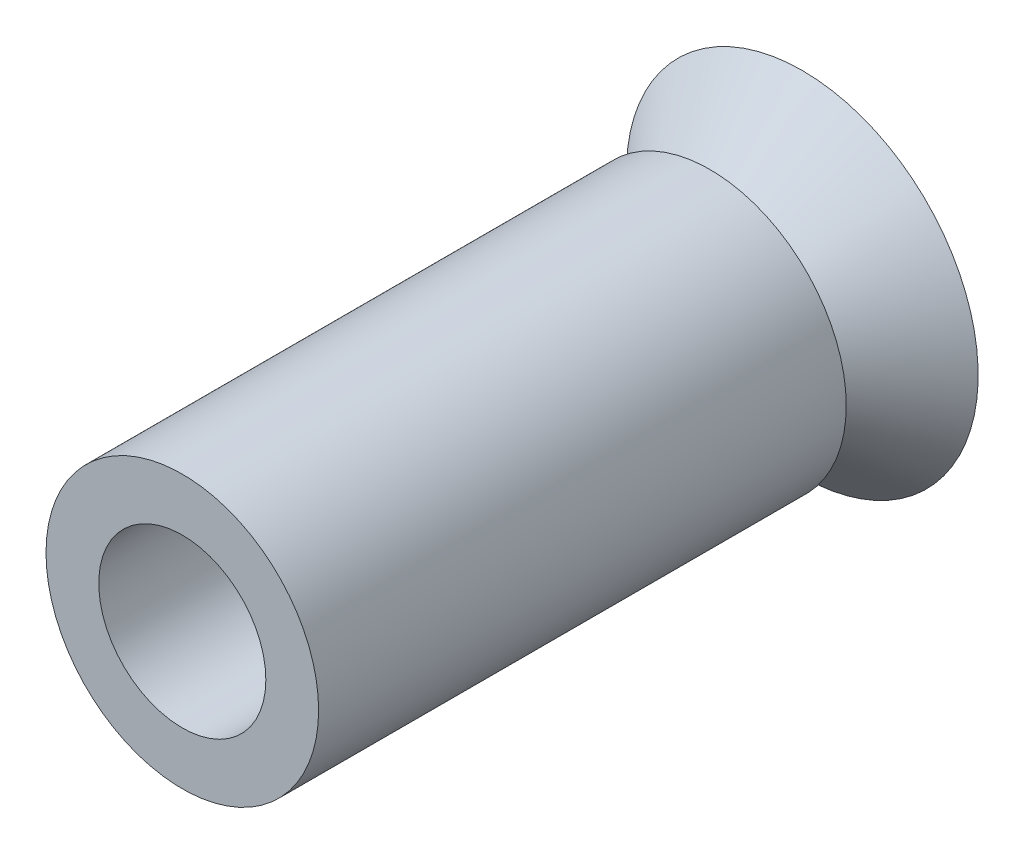
from build123d import *

# Parameters (mm, degrees)
BOSS_EXTRUDE1_START = -1.05
SKETCH5_R           = 0.95
BOSS_EXTRUDE1_DEPTH = 3
BOSS_EXTRUDE2_START = 0.7
SKETCH7_R           = 1.55
SKETCH7_R_2         = 0.95
BOSS_EXTRUDE2_DEPTH = 6


with BuildPart() as part:
    # Sketch3 → Revolve1 (revolve)
    with BuildSketch(Plane(origin=(0, 0, 0), x_dir=(0, 0, -1), z_dir=(1, 0, 0))):
        Polygon((0, 2), (-1.05, 0.95), (-1.05, 0), (0, 0), align=None)
    revolve(axis=Axis((0, 0, 0), (0, 0, 1)))

    # Sketch5 → Boss-Extrude1 (add)
    with BuildSketch(Plane.XY.offset(1.05).offset(BOSS_EXTRUDE1_START)):
        Circle(SKETCH5_R)
    extrude(amount=BOSS_EXTRUDE1_DEPTH)


with BuildPart() as body_2:
    # Sketch7 → Boss-Extrude2 (new body)
    with BuildSketch(Plane.XY.offset(0.35).offset(BOSS_EXTRUDE2_START)):
        Circle(SKETCH7_R)
        Circle(SKETCH7_R_2, mode=Mode.SUBTRACT)
    extrude(amount=BOSS_EXTRUDE2_DEPTH)


solid = Compound([part.part, body_2.part])
